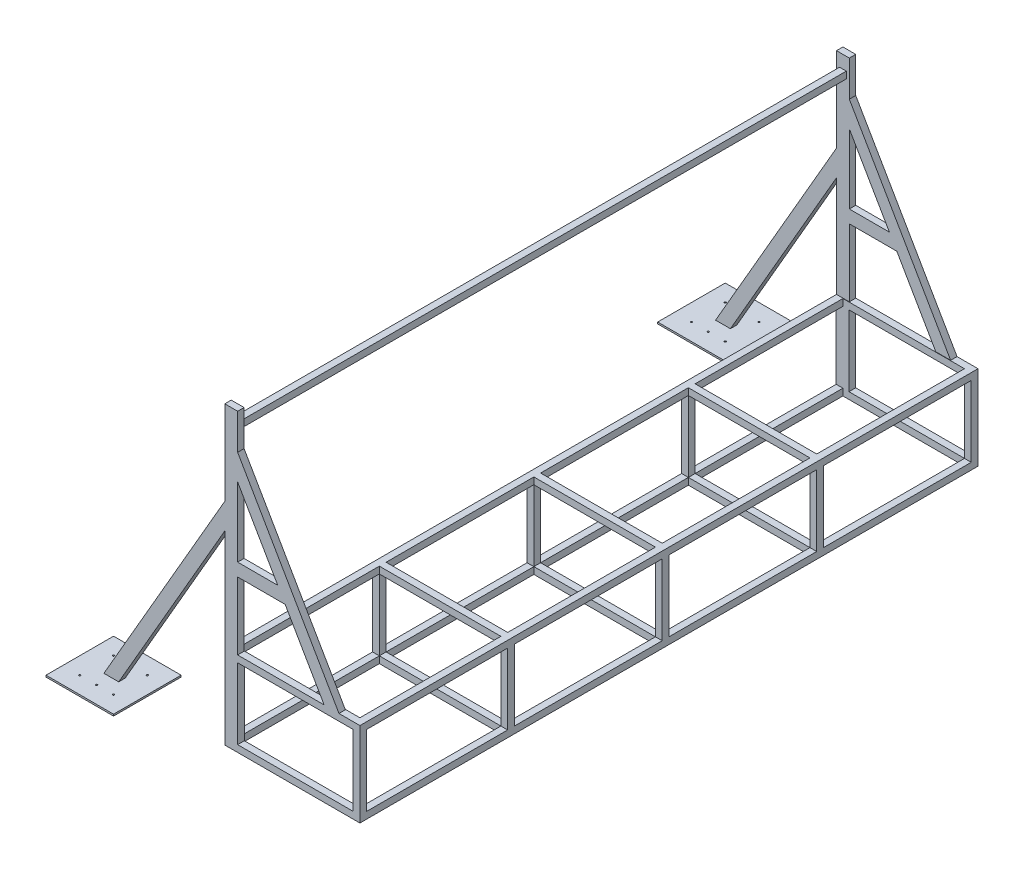
from build123d import *

# Parameters (mm, degrees)
SKETCH1_W               = 800
SKETCH1_H               = 500
BOSS_EXTRUDE5_DEPTH     = 3660
BOSS_EXTRUDE5_2_DEPTH   = 3660
BOSS_EXTRUDE2_DEPTH     = 38
SKETCH4_W               = 684
SKETCH4_H               = 420
CUT_EXTRUDE1_DEPTH      = 3661
CUT_EXTRUDE2_DEPTH      = 1790
CUT_EXTRUDE2_DEPTH_BACK = 1790
BOSS_EXTRUDE3_DEPTH     = 76
SKETCH9_W               = 400
SKETCH9_H               = 400
BOSS_EXTRUDE6_DEPTH     = 10
BOSS_EXTRUDE6_2_DEPTH   = 10
SKETCH11_W              = 40
SKETCH11_H              = 40
BOSS_EXTRUDE7_DEPTH     = 3584
SKETCH12_W              = 40
SKETCH12_H              = 40
BOSS_EXTRUDE8_DEPTH     = 420
LPATTERN1_COUNT         = 4
LPATTERN1_PITCH         = 915
LPATTERN1_COUNT_DIR2    = 2
LPATTERN1_PITCH_DIR2    = 760
SKETCH13_W              = 40
SKETCH13_H              = 40
BOSS_EXTRUDE9_DEPTH     = 760
LPATTERN2_COUNT         = 4
LPATTERN2_PITCH         = 915
LPATTERN2_COUNT_DIR2    = 2
LPATTERN2_PITCH_DIR2    = 460
SKETCH14_W              = 4140.847934345
SKETCH14_H              = 3535.849458551
CUT_EXTRUDE3_DEPTH      = 182
CUT_EXTRUDE3_DEPTH_BACK = 3842
SKETCH17_W              = 5
SKETCH17_H              = 10
LPATTERN3_COUNT         = 2
LPATTERN3_PITCH         = 200
LPATTERN3_COUNT_DIR2    = 3
LPATTERN3_PITCH_DIR2    = 100
MIRROR3_COPY_1_SKETCH_W = 5
MIRROR3_COPY_1_SKETCH_H = 10
MIRROR3_COPY_2_SKETCH_W = 5
MIRROR3_COPY_2_SKETCH_H = 10
MIRROR3_COPY_3_SKETCH_W = 5
MIRROR3_COPY_3_SKETCH_H = 10
MIRROR3_COPY_4_SKETCH_W = 5
MIRROR3_COPY_4_SKETCH_H = 10
MIRROR3_COPY_5_SKETCH_W = 5
MIRROR3_COPY_5_SKETCH_H = 10


with BuildPart() as part:
    # Sketch1 → Boss-Extrude5 (new body)
    with BuildSketch(Plane.XY):
        with Locations((400, 250)):
            Rectangle(SKETCH1_W, SKETCH1_H)
    extrude(amount=BOSS_EXTRUDE5_DEPTH)

    # Sketch3 → Boss-Extrude2 (add)
    with BuildSketch(Plane.XY):
        Polygon((0, 500), (76, 500), (76, 900), (357.302651407, 900), (588.242759083, 500), (676, 500), (76, 1539.230484541), (76, 1750), (0, 1750), (0, 1250), (-721.687836487, 0), (-633.93059557, 0), (0, 1098), align=None)
        Polygon((76, 1387.230484541), (313.424030949, 976), (76, 976), align=None, mode=Mode.SUBTRACT)
    boss_extrude2 = extrude(amount=BOSS_EXTRUDE2_DEPTH)

    # Mirror1: Boss-Extrude2 across plane
    add(boss_extrude2.mirror(Plane.XY.offset(1830)))

    # Sketch4 → Cut-Extrude1 (cut, through all)
    with BuildSketch(Plane.XY.offset(3660)):
        with Locations((418, 250)):
            Rectangle(SKETCH4_W, SKETCH4_H)
    extrude(amount=-CUT_EXTRUDE1_DEPTH, mode=Mode.SUBTRACT)

    # Sketch5 → Cut-Extrude2 (cut, two sides)
    with BuildSketch(Plane.XY.offset(1830)) as cut_extrude2_sk:
        Polygon((40, 500), (40, 460), (0, 460), (0, 40), (40, 40), (40, 0), (760, 0), (760, 40), (800, 40), (800, 460), (760, 460), (760, 500), align=None)
    extrude(amount=CUT_EXTRUDE2_DEPTH, mode=Mode.SUBTRACT)
    extrude(cut_extrude2_sk.sketch, amount=-CUT_EXTRUDE2_DEPTH_BACK, mode=Mode.SUBTRACT)

    # Sketch11 → Boss-Extrude7 (add)
    with BuildSketch(Plane.XY.offset(38)):
        with Locations((38, 1654)):
            Rectangle(SKETCH11_W, SKETCH11_H)
    extrude(amount=BOSS_EXTRUDE7_DEPTH)

    # Sketch12 → Boss-Extrude8 (add)
    with BuildSketch(Plane(origin=(0, 40, 0), x_dir=(1, 0, 0), z_dir=(0, 1, 0))):
        with Locations((20, -20)):
            Rectangle(SKETCH12_W, SKETCH12_H)
    boss_extrude8 = extrude(amount=BOSS_EXTRUDE8_DEPTH)

    # LPattern1: Boss-Extrude8 4 × 2
    with Locations(*[(j * LPATTERN1_PITCH_DIR2, 0, i * LPATTERN1_PITCH) for i in range(LPATTERN1_COUNT) for j in range(LPATTERN1_COUNT_DIR2) if (i, j) != (0, 0)]):
        add(boss_extrude8)

    # Sketch13 → Boss-Extrude9 (add)
    with BuildSketch(Plane.ZY.offset(-760)):
        with Locations((20, 480)):
            Rectangle(SKETCH13_W, SKETCH13_H)
    boss_extrude9 = extrude(amount=BOSS_EXTRUDE9_DEPTH)

    # LPattern2: Boss-Extrude9 4 × 2
    with Locations(*[(0, -j * LPATTERN2_PITCH_DIR2, i * LPATTERN2_PITCH) for i in range(LPATTERN2_COUNT) for j in range(LPATTERN2_COUNT_DIR2) if (i, j) != (0, 0)]):
        add(boss_extrude9)


with BuildPart() as body_2:
    # Sketch1 → Boss-Extrude5 2 (new body)
    with BuildSketch(Plane.XY):
        Polygon((2614.411542732, 3678.652977851), (2630, 3669.652977851), (800, 500), (784.411542732, 509), align=None)
    extrude(amount=BOSS_EXTRUDE5_2_DEPTH)


with BuildPart() as body_3:
    # Sketch7 → Boss-Extrude3 (new body)
    with BuildSketch(Plane(origin=(367.905191786, -212.410161514, 0), x_dir=(0, 0, 1), z_dir=(-0.866025404, 0.5, 0))):
        Polygon((1830, 833.012701892), (0, 833.012701892), (0, 4493.012701892), (1830, 4493.012701892), (1830, 4455.012701892), (38, 4455.012701892), (38, 871.012701892), (1830, 871.012701892), align=None)
    boss_extrude3 = extrude(amount=BOSS_EXTRUDE3_DEPTH)

    # Mirror2: Boss-Extrude3 across plane
    add(boss_extrude3.mirror(Plane.XY.offset(1830)))


with BuildPart() as body_4:
    # Sketch9 → Boss-Extrude6 (new body)
    with BuildSketch(Plane.XZ):
        with Locations((-677.809216029, 3641)):
            Rectangle(SKETCH9_W, SKETCH9_H)
    extrude(amount=-BOSS_EXTRUDE6_DEPTH)

    # Sketch17 → Ø10.0mm Dowel Hole1 (revolve, cut)
    with BuildSketch(Plane(origin=(-777.809216029, 10, 3541), x_dir=(0, 0, 1), z_dir=(1, 0, 0))):
        with Locations((2.5, 5)):
            Rectangle(SKETCH17_W, SKETCH17_H)
    f_10_0mm_dowel_hole1 = revolve(axis=Axis((-777.809216029, 16.35, 3541), (0, -1, 0)), mode=Mode.SUBTRACT)

    # LPattern3: 10.0mm Dowel Hole1 2 × 3
    with Locations(*[(j * LPATTERN3_PITCH_DIR2, 0, i * LPATTERN3_PITCH) for i in range(LPATTERN3_COUNT) for j in range(LPATTERN3_COUNT_DIR2) if (i, j) != (0, 0)]):
        add(f_10_0mm_dowel_hole1, mode=Mode.SUBTRACT)


with BuildPart() as body_5:
    # Sketch9 → Boss-Extrude6 2 (new body)
    with BuildSketch(Plane.XZ):
        with Locations((-677.809216029, 19)):
            Rectangle(SKETCH9_W, SKETCH9_H)
    extrude(amount=-BOSS_EXTRUDE6_2_DEPTH)

    # Mirror3: Ø10.0mm Dowel Hole1 across plane
    add(f_10_0mm_dowel_hole1.mirror(Plane.XY.offset(1830)), mode=Mode.SUBTRACT)

    # Mirror3 copy 1 sketch → Mirror3 copy 1 (revolve, cut)
    with BuildSketch(Plane(origin=(-677.809216029, 10, 119), x_dir=(0, 0, -1), z_dir=(1, 0, 0))):
        with Locations((2.5, -5)):
            Rectangle(MIRROR3_COPY_1_SKETCH_W, MIRROR3_COPY_1_SKETCH_H)
    revolve(axis=Axis((-677.809216029, 16.35, 119), (0, 1, 0)), mode=Mode.SUBTRACT)

    # Mirror3 copy 2 sketch → Mirror3 copy 2 (revolve, cut)
    with BuildSketch(Plane(origin=(-577.809216029, 10, 119), x_dir=(0, 0, -1), z_dir=(1, 0, 0))):
        with Locations((2.5, -5)):
            Rectangle(MIRROR3_COPY_2_SKETCH_W, MIRROR3_COPY_2_SKETCH_H)
    revolve(axis=Axis((-577.809216029, 16.35, 119), (0, 1, 0)), mode=Mode.SUBTRACT)

    # Mirror3 copy 3 sketch → Mirror3 copy 3 (revolve, cut)
    with BuildSketch(Plane(origin=(-777.809216029, 10, -81), x_dir=(0, 0, -1), z_dir=(1, 0, 0))):
        with Locations((2.5, -5)):
            Rectangle(MIRROR3_COPY_3_SKETCH_W, MIRROR3_COPY_3_SKETCH_H)
    revolve(axis=Axis((-777.809216029, 16.35, -81), (0, 1, 0)), mode=Mode.SUBTRACT)

    # Mirror3 copy 4 sketch → Mirror3 copy 4 (revolve, cut)
    with BuildSketch(Plane(origin=(-677.809216029, 10, -81), x_dir=(0, 0, -1), z_dir=(1, 0, 0))):
        with Locations((2.5, -5)):
            Rectangle(MIRROR3_COPY_4_SKETCH_W, MIRROR3_COPY_4_SKETCH_H)
    revolve(axis=Axis((-677.809216029, 16.35, -81), (0, 1, 0)), mode=Mode.SUBTRACT)

    # Mirror3 copy 5 sketch → Mirror3 copy 5 (revolve, cut)
    with BuildSketch(Plane(origin=(-577.809216029, 10, -81), x_dir=(0, 0, -1), z_dir=(1, 0, 0))):
        with Locations((2.5, -5)):
            Rectangle(MIRROR3_COPY_5_SKETCH_W, MIRROR3_COPY_5_SKETCH_H)
    revolve(axis=Axis((-577.809216029, 16.35, -81), (0, 1, 0)), mode=Mode.SUBTRACT)


with BuildPart() as cut_extrude3_tool:
    # Sketch14 → Cut-Extrude3 (new body, two sides)
    with BuildSketch(Plane.XY.offset(3660)) as cut_extrude3_sk:
        with Locations((2687.602754195, 2267.924729276)):
            Rectangle(SKETCH14_W, SKETCH14_H)
    extrude(amount=CUT_EXTRUDE3_DEPTH)
    extrude(cut_extrude3_sk.sketch, amount=-CUT_EXTRUDE3_DEPTH_BACK)


with BuildPart() as body_3_1:
    add(body_3.part)

    # Cut-Extrude3: cut by cut_extrude3_tool
    add(cut_extrude3_tool.part, mode=Mode.SUBTRACT)


with BuildPart() as body_2_1:
    add(body_2.part)

    # Cut-Extrude3: cut by cut_extrude3_tool
    add(cut_extrude3_tool.part, mode=Mode.SUBTRACT)


solid = Compound([part.part, body_4.part, body_5.part])
